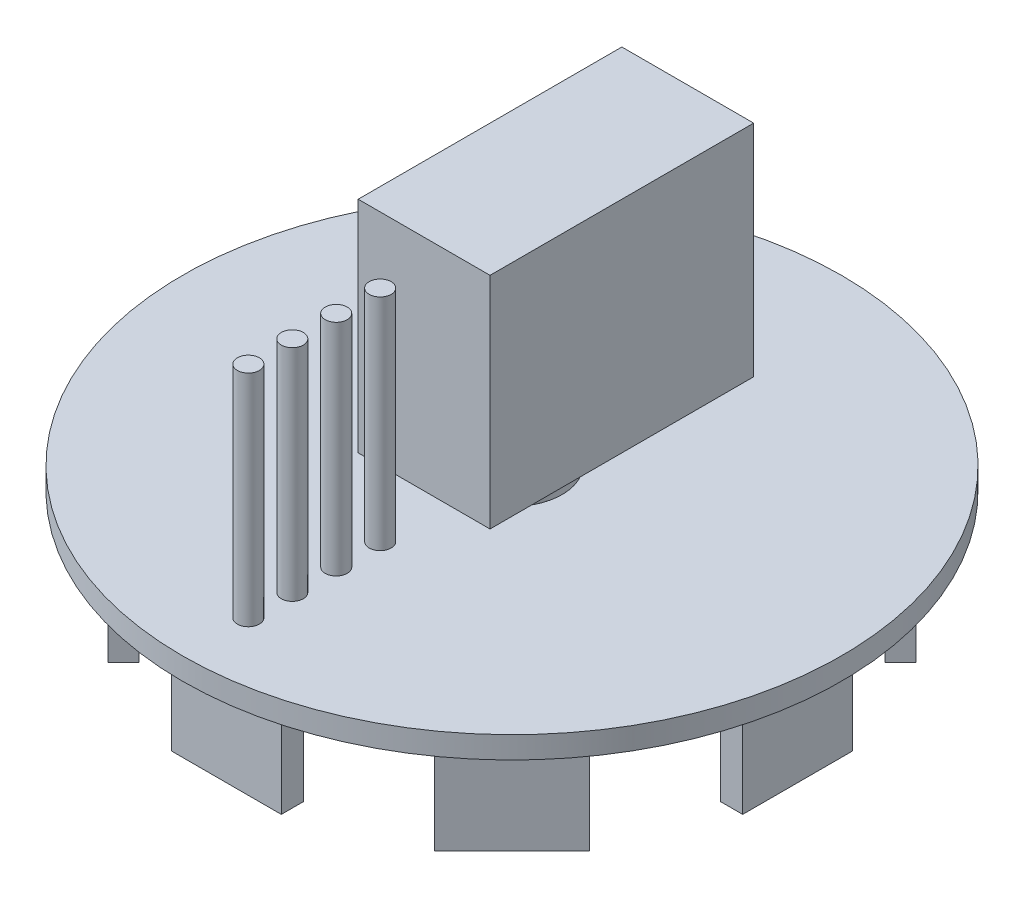
from build123d import *

# Parameters (mm, degrees)
BOSS_EXTRUDE1_DEPTH   = 25
BOSS_EXTRUDE1_2_DEPTH = 25
SKETCH1_W             = 25
SKETCH1_H             = 5
BOSS_EXTRUDE1_3_DEPTH = 25
BOSS_EXTRUDE1_4_DEPTH = 25
SKETCH1_W_2           = 5
SKETCH1_H_2           = 25
BOSS_EXTRUDE1_5_DEPTH = 25
BOSS_EXTRUDE1_6_DEPTH = 25
BOSS_EXTRUDE1_7_DEPTH = 25
BOSS_EXTRUDE1_8_DEPTH = 25
SKETCH2_R             = 75
BOSS_EXTRUDE2_DEPTH   = 5
SKETCH3_W             = 30
SKETCH3_H             = 30
BOSS_EXTRUDE3_DEPTH   = 5
SKETCH4_R             = 11.420268363
CUT_EXTRUDE1_DEPTH    = 5
SKETCH5_R             = 11.420268363
BOSS_EXTRUDE4_DEPTH   = 5
SKETCH6_W             = 30
SKETCH6_H             = 60
BOSS_EXTRUDE5_DEPTH   = 50
SKETCH7_R             = 2.5
BOSS_EXTRUDE6_DEPTH   = 50


with BuildPart() as part:
    # Sketch1 → Boss-Extrude1 (new body)
    with BuildSketch(Plane(origin=(0, 0, 0), x_dir=(1, 0, 0), z_dir=(0, 1, 0))):
        Polygon((-37.123106012, -54.800775542), (-33.587572106, -51.265241636), (-51.265241636, -33.587572106), (-54.800775542, -37.123106012), align=None)
    extrude(amount=BOSS_EXTRUDE1_DEPTH)



with BuildPart() as body_2:
    # Sketch1 → Boss-Extrude1 2 (new body)
    with BuildSketch(Plane(origin=(0, 0, 0), x_dir=(1, 0, 0), z_dir=(0, 1, 0))):
        Polygon((-54.800775542, 37.123106012), (-51.265241636, 33.587572106), (-33.587572106, 51.265241636), (-37.123106012, 54.800775542), align=None)
    extrude(amount=BOSS_EXTRUDE1_2_DEPTH)


with BuildPart() as body_3:
    # Sketch1 → Boss-Extrude1 3 (new body)
    with BuildSketch(Plane(origin=(0, 0, 0), x_dir=(1, 0, 0), z_dir=(0, 1, 0))):
        with Locations((0, 62.5)):
            Rectangle(SKETCH1_W, SKETCH1_H)
    extrude(amount=BOSS_EXTRUDE1_3_DEPTH)


with BuildPart() as body_4:
    # Sketch1 → Boss-Extrude1 4 (new body)
    with BuildSketch(Plane(origin=(0, 0, 0), x_dir=(1, 0, 0), z_dir=(0, 1, 0))):
        Polygon((37.123106012, 54.800775542), (33.587572106, 51.265241636), (51.265241636, 33.587572106), (54.800775542, 37.123106012), align=None)
    extrude(amount=BOSS_EXTRUDE1_4_DEPTH)


with BuildPart() as body_5:
    # Sketch1 → Boss-Extrude1 5 (new body)
    with BuildSketch(Plane(origin=(0, 0, 0), x_dir=(1, 0, 0), z_dir=(0, 1, 0))):
        with Locations((62.5, 0)):
            Rectangle(SKETCH1_W_2, SKETCH1_H_2)
    extrude(amount=BOSS_EXTRUDE1_5_DEPTH)


with BuildPart() as body_6:
    # Sketch1 → Boss-Extrude1 6 (new body)
    with BuildSketch(Plane(origin=(0, 0, 0), x_dir=(1, 0, 0), z_dir=(0, 1, 0))):
        Polygon((54.800775542, -37.123106012), (51.265241636, -33.587572106), (33.587572106, -51.265241636), (37.123106012, -54.800775542), align=None)
    extrude(amount=BOSS_EXTRUDE1_6_DEPTH)


with BuildPart() as body_7:
    # Sketch1 → Boss-Extrude1 7 (new body)
    with BuildSketch(Plane(origin=(0, 0, 0), x_dir=(1, 0, 0), z_dir=(0, 1, 0))):
        with Locations((0, -62.5)):
            Rectangle(SKETCH1_W, SKETCH1_H)
    extrude(amount=BOSS_EXTRUDE1_7_DEPTH)


with BuildPart() as body_8:
    # Sketch1 → Boss-Extrude1 8 (new body)
    with BuildSketch(Plane(origin=(0, 0, 0), x_dir=(1, 0, 0), z_dir=(0, 1, 0))):
        with Locations((-62.5, 0)):
            Rectangle(SKETCH1_W_2, SKETCH1_H_2)
    extrude(amount=BOSS_EXTRUDE1_8_DEPTH)


with BuildPart() as part_1:
    add(part.part)

    add(body_2.part)  # Boss-Extrude2 merges body 2

    add(body_3.part)  # Boss-Extrude2 merges body 3

    add(body_4.part)  # Boss-Extrude2 merges body 4

    add(body_5.part)  # Boss-Extrude2 merges body 5

    add(body_6.part)  # Boss-Extrude2 merges body 6

    add(body_7.part)  # Boss-Extrude2 merges body 7

    add(body_8.part)  # Boss-Extrude2 merges body 8
    # Sketch2 → Boss-Extrude2 (add)
    with BuildSketch(Plane(origin=(0, 25, 0), x_dir=(1, 0, 0), z_dir=(0, 1, 0))):
        Circle(SKETCH2_R)
    extrude(amount=BOSS_EXTRUDE2_DEPTH)

    # Sketch3 → Boss-Extrude3 (add)
    with BuildSketch(Plane.XZ.offset(-25)):
        with Locations((0, 35)):
            Rectangle(SKETCH3_W, SKETCH3_H)
    extrude(amount=BOSS_EXTRUDE3_DEPTH)

    # Sketch4 → Cut-Extrude1 (cut)
    with BuildSketch(Plane.XZ.offset(-25)):
        Circle(SKETCH4_R)
    extrude(amount=-CUT_EXTRUDE1_DEPTH, mode=Mode.SUBTRACT)

    # Sketch7 → Boss-Extrude6 (add)
    with BuildSketch(Plane(origin=(0, 30, 0), x_dir=(1, 0, 0), z_dir=(0, 1, 0))):
        with Locations((0, -30)):
            Circle(SKETCH7_R)
        with Locations((0, -40)):
            Circle(SKETCH7_R)
        with Locations((0, -50)):
            Circle(SKETCH7_R)
        with Locations((0, -60)):
            Circle(SKETCH7_R)
    extrude(amount=BOSS_EXTRUDE6_DEPTH)


with BuildPart() as body_2_2:
    # Sketch5 → Boss-Extrude4 (new body)
    with BuildSketch(Plane(origin=(0, 30, 0), x_dir=(1, 0, 0), z_dir=(0, 1, 0))):
        Circle(SKETCH5_R)
    extrude(amount=BOSS_EXTRUDE4_DEPTH)

    # Sketch6 → Boss-Extrude5 (add)
    with BuildSketch(Plane(origin=(0, 35, 0), x_dir=(1, 0, 0), z_dir=(0, 1, 0))):
        with Locations((0, 10)):
            Rectangle(SKETCH6_W, SKETCH6_H)
    extrude(amount=BOSS_EXTRUDE5_DEPTH)


solid = Compound([part_1.part, body_2_2.part])
